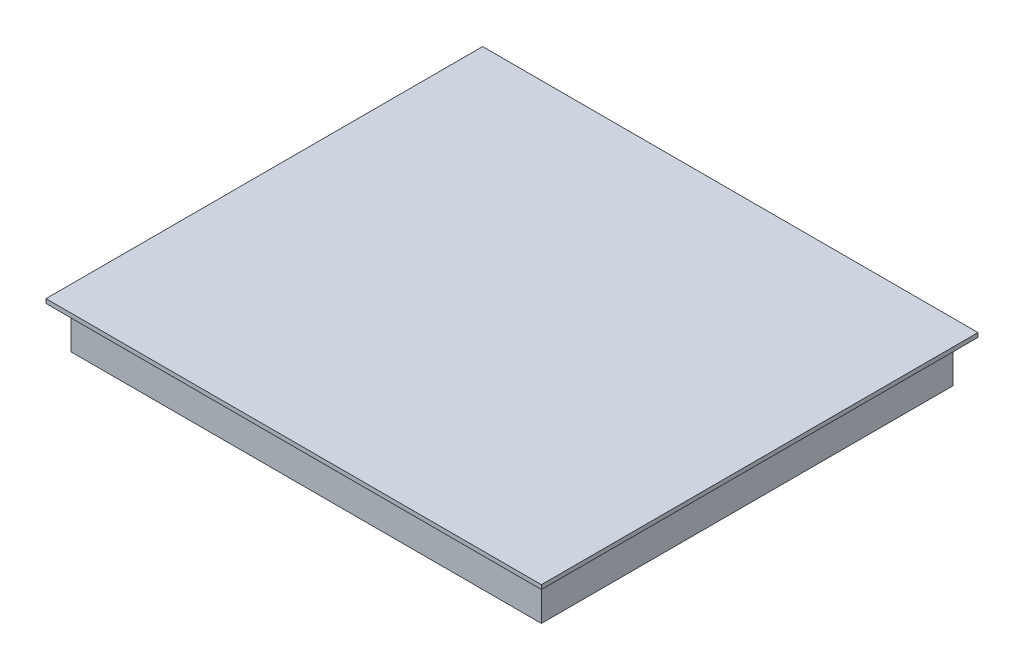
from build123d import *

# Parameters (mm, degrees)
SKETCH_1_W      = 560
SKETCH_1_H      = 490
EXTRUDE_1_DEPTH = 50
SKETCH_2_W      = 590
SKETCH_2_H      = 520
EXTRUDE_2_DEPTH = 5


with BuildPart() as part:
    # Эскиз1 → Бобышка-Вытянуть1 (new body)
    with BuildSketch(Plane(origin=(0, 0, 0), x_dir=(1, 0, 0), z_dir=(0, 1, 0))):
        Rectangle(SKETCH_1_W, SKETCH_1_H)
    extrude(amount=EXTRUDE_1_DEPTH)

    # Эскиз2 → Бобышка-Вытянуть2 (add)
    with BuildSketch(Plane(origin=(0, 50, 0), x_dir=(1, 0, 0), z_dir=(0, 1, 0))):
        Rectangle(SKETCH_2_W, SKETCH_2_H)
    extrude(amount=EXTRUDE_2_DEPTH)


solid = part.part
